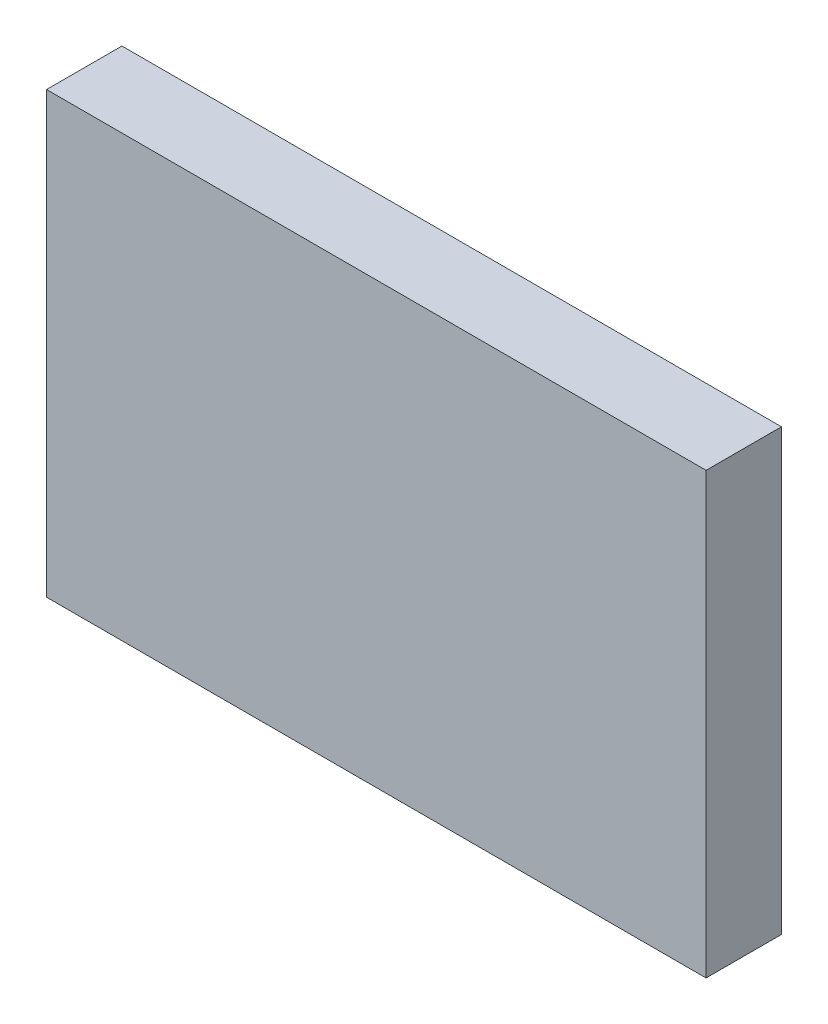
from build123d import *

# Parameters (mm, degrees)
SKETCH1_W           = 84
SKETCH1_H           = 56
BOSS_EXTRUDE1_DEPTH = 9.6


with BuildPart() as part:
    # Sketch1 → Boss-Extrude1 (new body)
    with BuildSketch(Plane.XY):
        with Locations((42, 28)):
            Rectangle(SKETCH1_W, SKETCH1_H)
    extrude(amount=BOSS_EXTRUDE1_DEPTH)


solid = part.part
